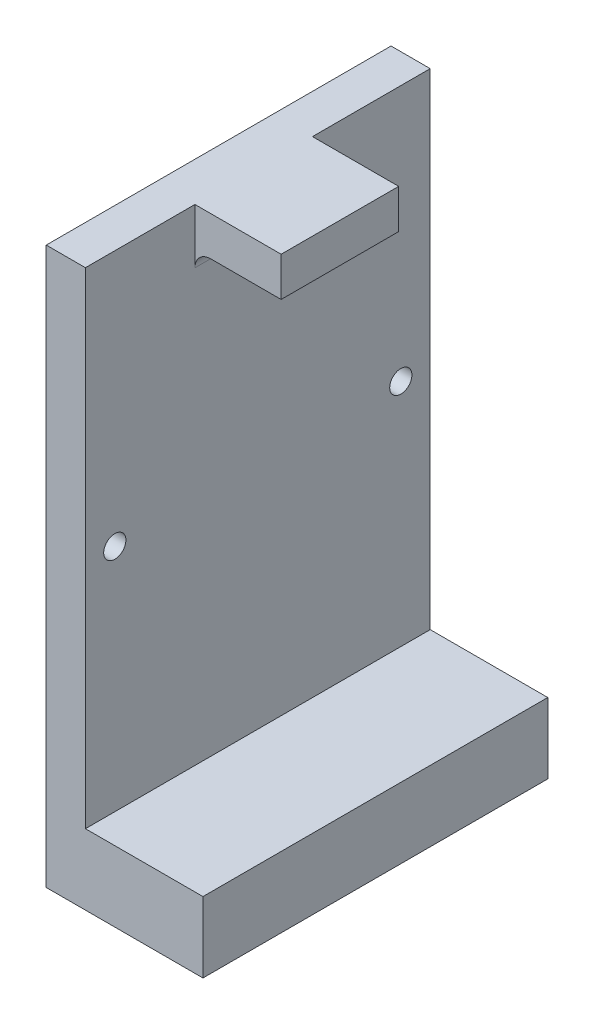
from build123d import *

# Parameters (mm, degrees)
SKETCH1_W            = 25.4
SKETCH1_H            = 55.88
BOSS_EXTRUDE1_DEPTH  = 11.43
SKETCH3_W            = 6.35
SKETCH3_H            = 55.88
BOSS_EXTRUDE2_DEPTH  = 78.74
SKETCH4_W            = 19.05
SKETCH4_H            = 6.35
BOSS_EXTRUDE3_DEPTH  = 13.97
M3_CLEARANCE_HOLE1_D = 3.6
FILLET1_R            = 2.54


with BuildPart() as part:
    # Sketch1 → Boss-Extrude1 (new body)
    with BuildSketch(Plane(origin=(0, 0, 0), x_dir=(1, 0, 0), z_dir=(0, 1, 0))):
        with Locations((-12.7, 27.94)):
            Rectangle(SKETCH1_W, SKETCH1_H)
    extrude(amount=BOSS_EXTRUDE1_DEPTH)

    # Sketch3 → Boss-Extrude2 (add)
    with BuildSketch(Plane(origin=(0, 11.43, 0), x_dir=(1, 0, 0), z_dir=(0, 1, 0))):
        with Locations((-22.225, 27.94)):
            Rectangle(SKETCH3_W, SKETCH3_H)
    extrude(amount=BOSS_EXTRUDE2_DEPTH)

    # Sketch4 → Boss-Extrude3 (add)
    with BuildSketch(Plane(origin=(-19.05, 0, 0), x_dir=(0, 0, -1), z_dir=(1, 0, 0))):
        with Locations((27.274464597, 86.995)):
            Rectangle(SKETCH4_W, SKETCH4_H)
    extrude(amount=BOSS_EXTRUDE3_DEPTH)

    # M3 Clearance Hole1 (through all)
    with Locations(Plane(origin=(-19.05, 0, 0), x_dir=(0, 0, -1), z_dir=(1, 0, 0))):
        with Locations((4.7625, 48.667276481), (51.1175, 48.667276481)):
            Hole(M3_CLEARANCE_HOLE1_D / 2)

    # Fillet1
    fillet1_edges = [part.edges().sort_by_distance(p)[0] for p in [
        (-19.05, 83.82, -27.274464597),
    ]]
    fillet(fillet1_edges, radius=FILLET1_R)


solid = part.part
